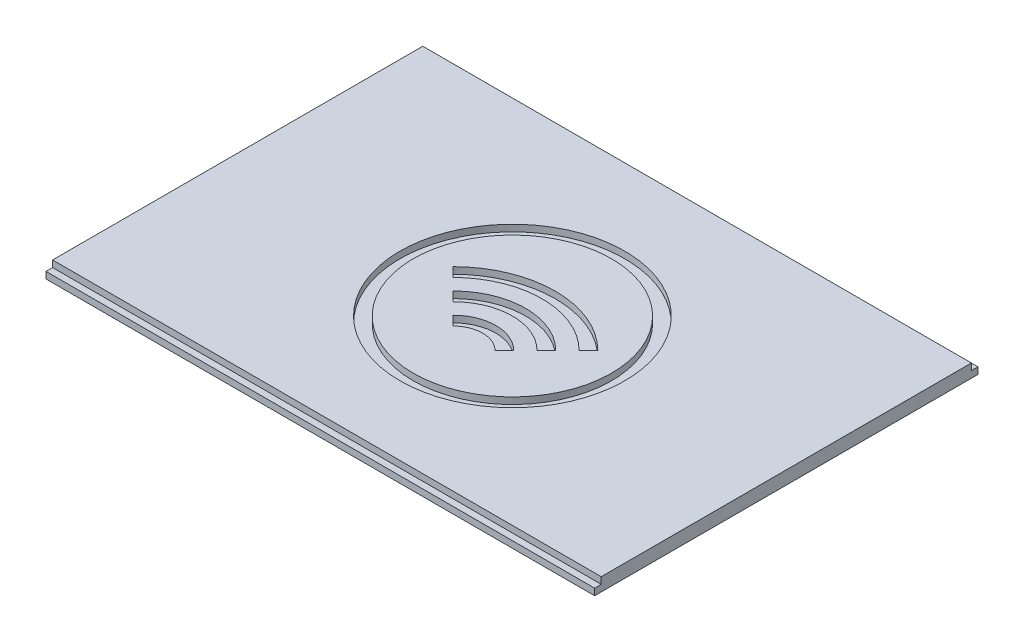
from build123d import *

# Parameters (mm, degrees)
SKIZZE1_W                       = 83
SKIZZE1_H                       = 58
AUFSATZ_LINEAR_AUSTRAGEN1_DEPTH = 2
SKIZZE2_W                       = 83
SKIZZE2_H                       = 1
SCHNITT_LINEAR_AUSTRAGEN1_DEPTH = 1
SKIZZE3_R                       = 17
SKIZZE3_R_2                     = 15
SCHNITT_LINEAR_AUSTRAGEN2_DEPTH = 1


with BuildPart() as part:
    # Skizze1 → Aufsatz-Linear austragen1 (new body)
    with BuildSketch(Plane(origin=(0, 0, 0), x_dir=(1, 0, 0), z_dir=(0, 1, 0))):
        with Locations((41.5, 29)):
            Rectangle(SKIZZE1_W, SKIZZE1_H)
    extrude(amount=AUFSATZ_LINEAR_AUSTRAGEN1_DEPTH)

    # Skizze2 → Schnitt-Linear austragen1 (cut)
    with BuildSketch(Plane(origin=(0, 2, 0), x_dir=(1, 0, 0), z_dir=(0, 1, 0))):
        with Locations((41.5, 57.5)):
            Rectangle(SKIZZE2_W, SKIZZE2_H)
        with Locations((41.5, 0.5)):
            Rectangle(SKIZZE2_W, SKIZZE2_H)
    extrude(amount=-SCHNITT_LINEAR_AUSTRAGEN1_DEPTH, mode=Mode.SUBTRACT)

    # Skizze3 → Schnitt-Linear austragen2 (cut)
    with BuildSketch(Plane(origin=(0, 2, 0), x_dir=(1, 0, 0), z_dir=(0, 1, 0))):
        with Locations((42.119824852, 28.44050911)):
            Circle(SKIZZE3_R)
        with Locations((42.119824852, 28.44050911)):
            Circle(SKIZZE3_R_2, mode=Mode.SUBTRACT)
        with BuildLine():
            ThreePointArc((31.159669744, 30.400664218), (42.119824852, 34.94050911), (53.079979961, 30.400664218))
            Line((53.079979961, 30.400664218), (51.665766398, 28.986450656))
            ThreePointArc((51.665766398, 28.986450656), (42.119824852, 32.94050911), (32.573883306, 28.986450656))
            Line((32.573883306, 28.986450656), (31.159669744, 30.400664218))
        make_face()
        with BuildLine():
            Line((35.755863822, 25.80447014), (34.341650259, 27.218683703))
            ThreePointArc((34.341650259, 27.218683703), (42.119824852, 30.44050911), (49.897999445, 27.218683703))
            Line((49.897999445, 27.218683703), (48.483785883, 25.80447014))
            ThreePointArc((48.483785883, 25.80447014), (42.119824852, 28.44050911), (35.755863822, 25.80447014))
        make_face()
        with BuildLine():
            Line((38.937844337, 22.622489625), (37.523630775, 24.036703187))
            ThreePointArc((37.523630775, 24.036703187), (42.119824852, 25.94050911), (46.71601893, 24.036703187))
            Line((46.71601893, 24.036703187), (45.301805368, 22.622489625))
            ThreePointArc((45.301805368, 22.622489625), (42.119824852, 23.94050911), (38.937844337, 22.622489625))
        make_face()
    extrude(amount=-SCHNITT_LINEAR_AUSTRAGEN2_DEPTH, mode=Mode.SUBTRACT)


solid = part.part
